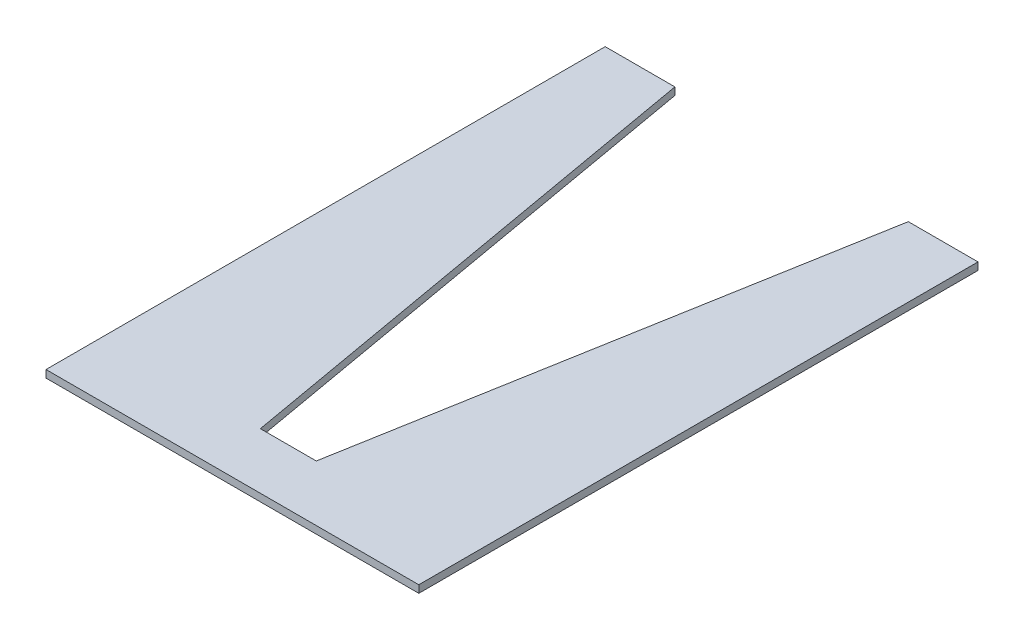
from build123d import *

# Parameters (mm, degrees)
BOSS_EXTRUDE1_DEPTH = 4


with BuildPart() as part:
    # Sketch1 → Boss-Extrude1 (new body)
    with BuildSketch(Plane(origin=(0, 0, 0), x_dir=(1, 0, 0), z_dir=(0, 1, 0))):
        Polygon((-100, 292.439319993), (-100, -7.560680007), (100, -7.560680007), (100, 292.439319993), (62.608284791, 292.439319993), (15, 22.439319993), (-15, 22.439319993), (-62.608284791, 292.439319993), align=None)
    extrude(amount=BOSS_EXTRUDE1_DEPTH)


solid = part.part
